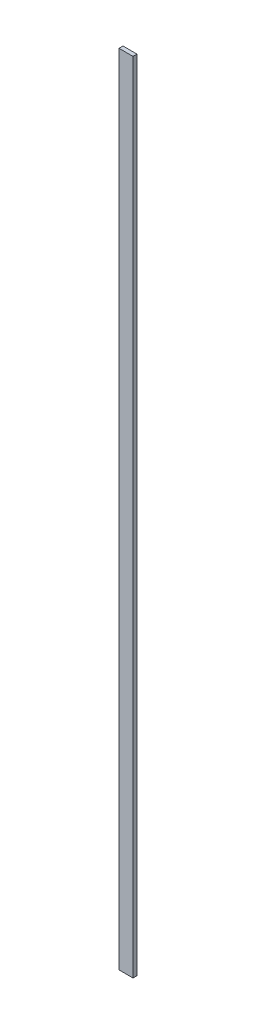
from build123d import *

# Parameters (mm, degrees)
ESQUISSE1_W        = 7
ESQUISSE1_H        = 400
BOSS_EXTRU_1_DEPTH = 2


with BuildPart() as part:
    # Esquisse1 → Boss.-Extru.1 (new body)
    with BuildSketch(Plane.XY):
        with Locations((-18.238806287, -166.081818182)):
            Rectangle(ESQUISSE1_W, ESQUISSE1_H)
    extrude(amount=BOSS_EXTRU_1_DEPTH)


solid = part.part
